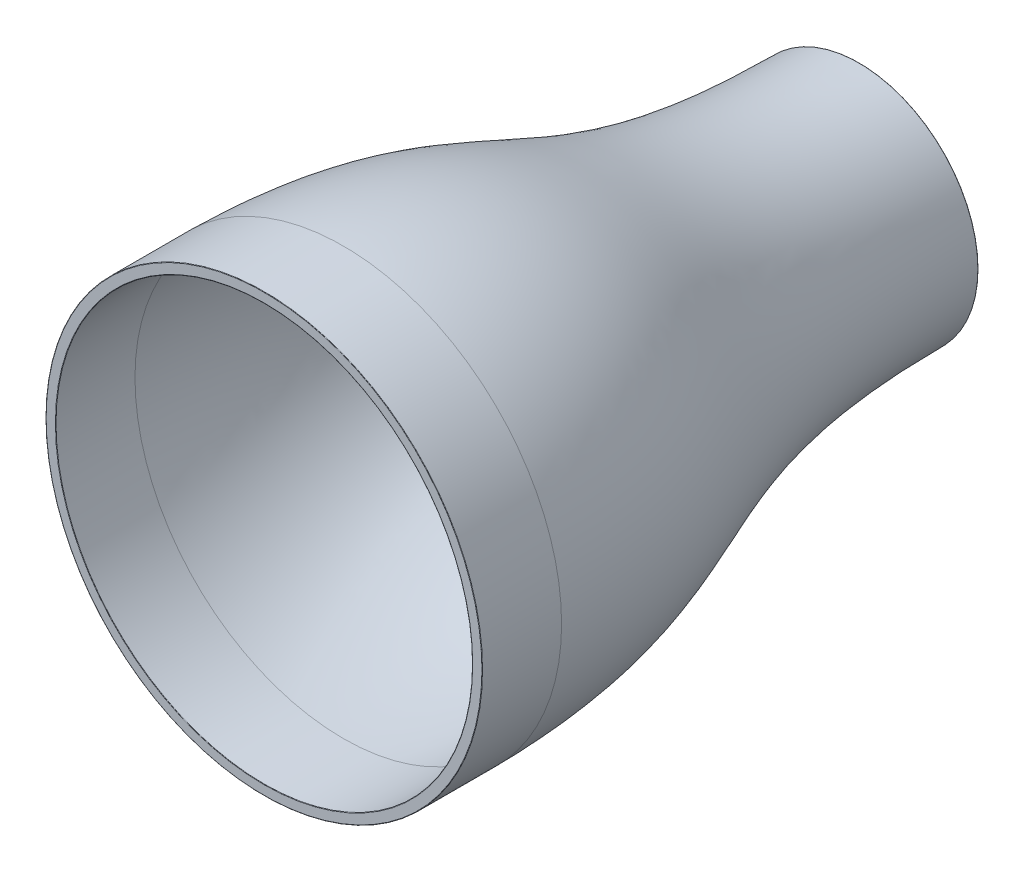
from build123d import *

# Parameters (mm, degrees)
SKETCH3_R          = 55
CUT_EXTRUDE1_DEPTH = 301
FILLET1_R          = 0.2


with BuildPart() as part:
    # Sketch1 → Revolve1 (revolve)
    with BuildSketch(Plane(origin=(0, 0, 0), x_dir=(0, 0, -1), z_dir=(1, 0, 0))):
        Polygon((40, 110), (0, 110), (0, 105), (39.962075489, 105), (40, 105), align=None)
        with BuildLine():
            add(Edge.make_bspline(
                [(40, 110), (167.810260187, 108.065881674), (157.727730686, 60.110887647), (300, 60)],
                knots=[0, 0, 0, 0, 1, 1, 1, 1], degree=3))
            Line((40, 110), (40, 105))
            Line((40, 105), (39.962075489, 105))
            add(Edge.make_bspline(
                [(39.962075489, 105), (40.929960137, 104.985279631), (42.889640848, 104.94977384), (46.725264587, 104.857338815), (51.42229057, 104.700972371), (56.863552667, 104.451154588), (63.874803799, 104.038009353), (72.195159933, 103.377081586), (81.524927631, 102.370461384), (90.254463852, 101.167896472), (101.167419574, 99.32622961), (113.586002402, 96.620016504), (126.985333476, 92.855675215), (139.338719286, 88.695720496), (151.098628178, 84.257785223), (162.706347452, 79.664487009), (174.588858932, 75.050832351), (187.158880915, 70.565269184), (200.817492413, 66.363871547), (215.959791253, 62.601742323), (230.145053896, 59.956252343), (242.63508141, 58.203877587), (252.624857821, 57.088589246), (261.817748058, 56.313227436), (267.760458444, 55.935197653), (270, 55.809372848)],
                knots=[0.000100222, 0.000100222, 0.000100222, 0.000100222, 0.0078125, 0.015625, 0.03125, 0.046875, 0.0625, 0.09375, 0.125, 0.15625, 0.1875, 0.25, 0.3125, 0.375, 0.4375, 0.5, 0.5625, 0.625, 0.6875, 0.75, 0.8125, 0.84375, 0.875, 0.90625, 0.924568143, 0.924568143, 0.924568143, 0.924568143], degree=3))
            Line((270, 55.809372848), (270, 60))
            Line((270, 60), (300, 60))
        make_face()
        Polygon((300, 0), (300, 60), (270, 60), (270, 55.809372848), (270, 0), align=None)
    revolve(axis=Axis((0, 0, 0), (0, 0, -1)))

    # Sketch3 → Cut-Extrude1 (cut, through all)
    with BuildSketch(Plane(origin=(0, 0, -300), x_dir=(-1, 0, 0), z_dir=(0, 0, -1))):
        Circle(SKETCH3_R)
    extrude(amount=-CUT_EXTRUDE1_DEPTH, mode=Mode.SUBTRACT)

    # Fillet1
    fillet1_edges = [part.edges().sort_by_distance(p)[0] for p in [
        (55, 0, -300),
        (0, -105, 0),
        (0, -110, 0),
        (0, -60, -300),
    ]]
    fillet(fillet1_edges, radius=FILLET1_R)


solid = part.part
